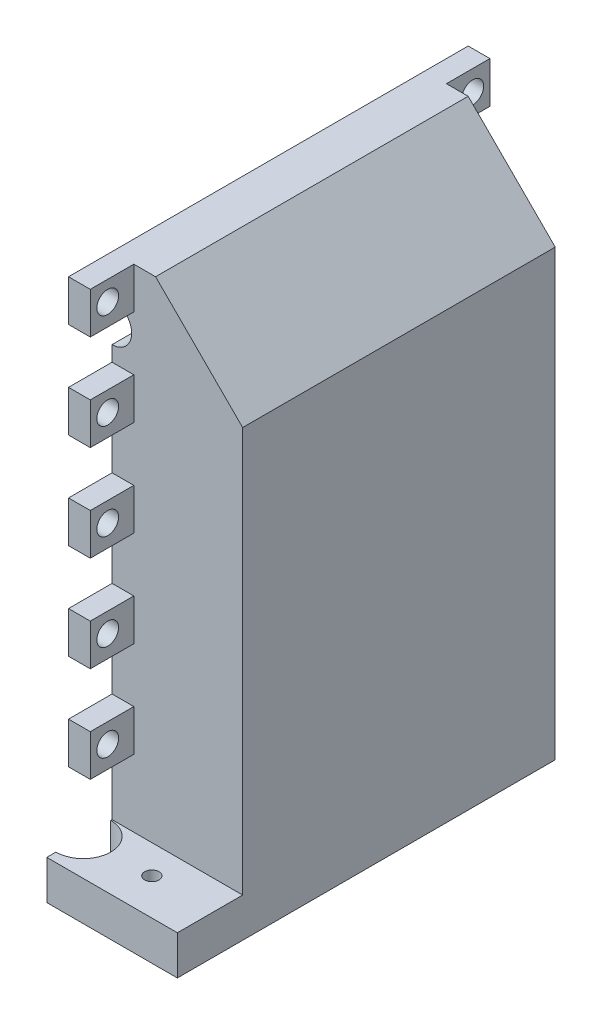
from build123d import *

# Parameters (mm, degrees)
SKETCH1_R                       = 2.54
BOSS_EXTRUDE1_DEPTH             = 11.43
BOSS_EXTRUDE2_DEPTH             = 107.95
SKETCH3_W                       = 38.1
SKETCH3_H                       = 91.186
BOSS_EXTRUDE3_DEPTH             = 35.56
CUT_EXTRUDE1_REACH              = 93.186
SKETCH4_R                       = 5.715
SKETCH5_W                       = 6.35
SKETCH5_H                       = 12.065
BOSS_EXTRUDE4_DEPTH             = 12.7
F_1_4_0_25_DIAMETER_HOLE2_D     = 6.35
F_1_4_0_25_DIAMETER_HOLE2_DEPTH = 6.351
LPATTERN2_COUNT                 = 5
LPATTERN2_PITCH                 = 27.94
SKETCH13_W                      = 6.35
SKETCH13_H                      = 11.43
BOSS_EXTRUDE5_DEPTH             = 12.7
F_1_4_0_25_DIAMETER_HOLE3_D     = 6.35
F_1_4_0_25_DIAMETER_HOLE3_DEPTH = 6.35
SKETCH16_W                      = 6.35
SKETCH16_H                      = 12.065
BOSS_EXTRUDE6_DEPTH             = 12.7
F_1_4_0_25_DIAMETER_HOLE4_D     = 6.35
F_1_4_0_25_DIAMETER_HOLE4_DEPTH = 6.35
SKETCH19_W                      = 6.35
SKETCH19_H                      = 12.065
BOSS_EXTRUDE7_DEPTH             = 12.7
F_1_4_0_25_DIAMETER_HOLE5_D     = 6.35
F_1_4_0_25_DIAMETER_HOLE5_DEPTH = 6.35
CHAMFER1_SIZE                   = 25.4
TAP_DRILL_FOR_M5X0_8_TAP1_D     = 4.2
TAP_DRILL_FOR_M5X0_8_TAP1_DEPTH = 11.43
CUT_EXTRUDE2_REACH              = 156.94
SKETCH24_R                      = 8


with BuildPart() as part:
    # Sketch1 → Boss-Extrude1 (new body)
    with BuildSketch(Plane(origin=(0, 0, 0), x_dir=(1, 0, 0), z_dir=(0, 1, 0))):
        with BuildLine():
            Line((0, 0), (14.605, 0))
            ThreePointArc((14.605, 0), (21.080049256, 8.637950744), (29.718, 15.113))
            Line((29.718, 15.113), (29.718, 44.323))
            ThreePointArc((29.718, 44.323), (21.080049256, 50.798049256), (14.605, 59.436))
            Line((14.605, 59.436), (0, 59.436))
            Line((0, 59.436), (0, 84.836))
            Line((0, 84.836), (38.1, 84.836))
            Line((38.1, 84.836), (38.1, -25.4))
            Line((38.1, -25.4), (0, -25.4))
            Line((0, -25.4), (0, 0))
        make_face()
        with Locations((23.622, 6.096)):
            Circle(SKETCH1_R, mode=Mode.SUBTRACT)
        with Locations((23.622, 53.34)):
            Circle(SKETCH1_R, mode=Mode.SUBTRACT)
    extrude(amount=BOSS_EXTRUDE1_DEPTH)

    # Sketch2 → Boss-Extrude2 (add)
    with BuildSketch(Plane(origin=(0, 11.43, 0), x_dir=(1, 0, 0), z_dir=(0, 1, 0))):
        Polygon((38.1, 84.836), (29.718, 84.836), (29.718, 0), (0, 0), (0, -6.35), (38.1, -6.35), align=None)
    extrude(amount=BOSS_EXTRUDE2_DEPTH)

    # Sketch3 → Boss-Extrude3 (add)
    with BuildSketch(Plane(origin=(0, 119.38, 0), x_dir=(1, 0, 0), z_dir=(0, 1, 0))):
        with Locations((19.05, 39.243)):
            Rectangle(SKETCH3_W, SKETCH3_H)
    extrude(amount=BOSS_EXTRUDE3_DEPTH)

    # Sketch4 → Cut-Extrude1 (cut, up to next)
    with BuildSketch(Plane.XY.offset(6.35), mode=Mode.PRIVATE) as cut_extrude1_sk1:
        with Locations((0, 137.16)):
            Circle(SKETCH4_R)
    cut_extrude1_tool1 = extrude(cut_extrude1_sk1.sketch, amount=-CUT_EXTRUDE1_REACH, mode=Mode.PRIVATE) & part.part
    add(cut_extrude1_tool1.solids().sort_by_distance((0, 137.16, 6.35))[0], mode=Mode.SUBTRACT)

    # Sketch5 → Boss-Extrude4 (add)
    with BuildSketch(Plane.XY.offset(6.35)):
        with Locations((3.175, 148.9075)):
            Rectangle(SKETCH5_W, SKETCH5_H)
    boss_extrude4 = extrude(amount=BOSS_EXTRUDE4_DEPTH)

    # 1/4 (0.25) Diameter Hole2
    with Locations(Plane(origin=(6.35, 0, 0), x_dir=(0, 0, -1), z_dir=(1, 0, 0))):
        with Locations((-13.97, 149.225)):
            f_1_4_0_25_diameter_hole2 = Hole(F_1_4_0_25_DIAMETER_HOLE2_D / 2, depth=F_1_4_0_25_DIAMETER_HOLE2_DEPTH)

    # LPattern2: Boss-Extrude4, 1/4 (0.25) Diameter Hole2 ×5
    with Locations(*[(0, -i * LPATTERN2_PITCH, 0) for i in range(1, LPATTERN2_COUNT)]):
        add(boss_extrude4)
        add(f_1_4_0_25_diameter_hole2, mode=Mode.SUBTRACT)

    # Sketch13 → Boss-Extrude5 (add)
    with BuildSketch(Plane(origin=(0, 0, -84.836), x_dir=(-1, 0, 0), z_dir=(0, 0, -1))):
        with Locations((-3.175, 5.715)):
            Rectangle(SKETCH13_W, SKETCH13_H)
    extrude(amount=BOSS_EXTRUDE5_DEPTH)

    # 1/4 (0.25) Diameter Hole3
    with Locations(Plane(origin=(6.35, 0, 0), x_dir=(0, 0, -1), z_dir=(1, 0, 0))):
        with Locations((92.456, 5.715)):
            Hole(F_1_4_0_25_DIAMETER_HOLE3_D / 2, depth=F_1_4_0_25_DIAMETER_HOLE3_DEPTH)

    # Sketch16 → Boss-Extrude6 (add)
    with BuildSketch(Plane(origin=(0, 0, -84.836), x_dir=(-1, 0, 0), z_dir=(0, 0, -1))):
        with Locations((-3.175, 148.9075)):
            Rectangle(SKETCH16_W, SKETCH16_H)
    extrude(amount=BOSS_EXTRUDE6_DEPTH)

    # 1/4 (0.25) Diameter Hole4
    with Locations(Plane(origin=(6.35, 0, 0), x_dir=(0, 0, -1), z_dir=(1, 0, 0))):
        with Locations((92.515604356, 148.9075)):
            Hole(F_1_4_0_25_DIAMETER_HOLE4_D / 2, depth=F_1_4_0_25_DIAMETER_HOLE4_DEPTH)

    # Sketch19 → Boss-Extrude7 (add)
    with BuildSketch(Plane(origin=(0, 0, -84.836), x_dir=(-1, 0, 0), z_dir=(0, 0, -1))):
        with Locations((-3.175, 125.4125)):
            Rectangle(SKETCH19_W, SKETCH19_H)
    extrude(amount=BOSS_EXTRUDE7_DEPTH)

    # 1/4 (0.25) Diameter Hole5
    with Locations(Plane(origin=(6.35, 0, 0), x_dir=(0, 0, -1), z_dir=(1, 0, 0))):
        with Locations((92.456, 125.4125)):
            Hole(F_1_4_0_25_DIAMETER_HOLE5_D / 2, depth=F_1_4_0_25_DIAMETER_HOLE5_DEPTH)

    # Chamfer1
    chamfer1_edges = [part.edges().sort_by_distance(p)[0] for p in [
        (38.1, 154.94, -39.243),
    ]]
    chamfer(chamfer1_edges, length=CHAMFER1_SIZE)

    # Tap Drill for M5x0.8 Tap1
    with Locations(Plane(origin=(0, 0, 0), x_dir=(-1, 0, 0), z_dir=(0, -1, 0))):
        with Locations((-20, 74.168), (-20, -14.732)):
            Hole(TAP_DRILL_FOR_M5X0_8_TAP1_D / 2, depth=TAP_DRILL_FOR_M5X0_8_TAP1_DEPTH)

    # Sketch24 → Cut-Extrude2 (cut, up to next)
    with BuildSketch(Plane.XZ, mode=Mode.PRIVATE) as cut_extrude2_sk1:
        with Locations((0, -74.168)):
            Circle(SKETCH24_R)
    cut_extrude2_tool1 = extrude(cut_extrude2_sk1.sketch, amount=-CUT_EXTRUDE2_REACH, mode=Mode.PRIVATE) & part.part
    add(cut_extrude2_tool1.solids().sort_by_distance((0, 0, -74.168))[0], mode=Mode.SUBTRACT)
    # Sketch24 → Cut-Extrude2 (cut, up to next)
    with BuildSketch(Plane.XZ, mode=Mode.PRIVATE) as cut_extrude2_sk2:
        with Locations((0, 14.732)):
            Circle(SKETCH24_R)
    cut_extrude2_tool2 = extrude(cut_extrude2_sk2.sketch, amount=-CUT_EXTRUDE2_REACH, mode=Mode.PRIVATE) & part.part
    add(cut_extrude2_tool2.solids().sort_by_distance((0, 0, 14.732))[0], mode=Mode.SUBTRACT)


solid = part.part
